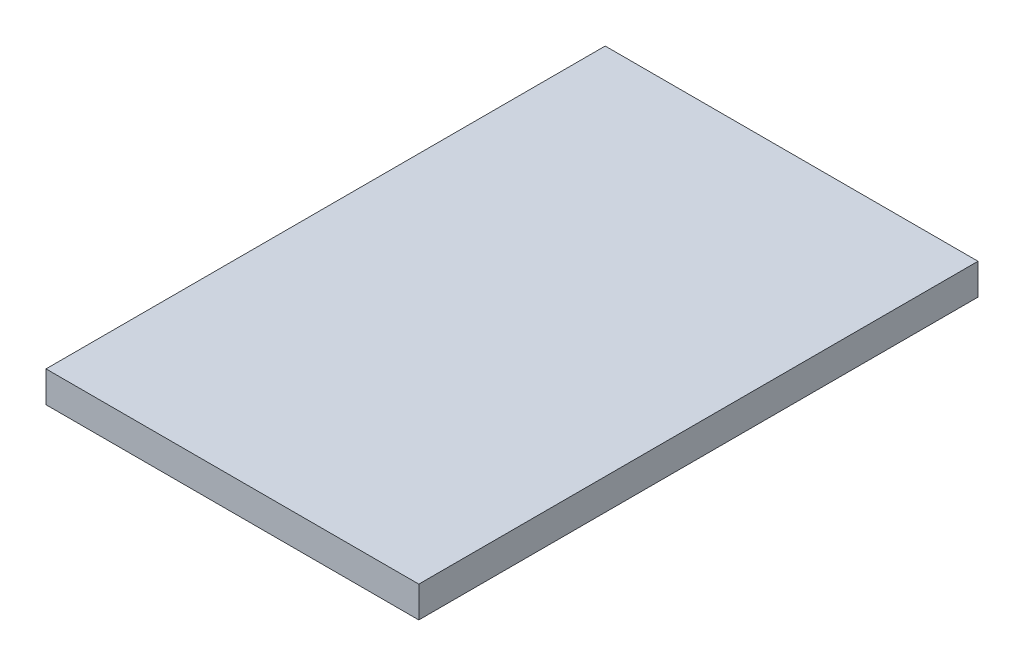
from build123d import *

# Parameters (mm, degrees)
SKETCH1_W           = 304.8
SKETCH1_H           = 25.4
BOSS_EXTRUDE1_DEPTH = 457.2


with BuildPart() as part:
    # Sketch1 → Boss-Extrude1 (new body)
    with BuildSketch(Plane.XY):
        Rectangle(SKETCH1_W, SKETCH1_H)
    extrude(amount=BOSS_EXTRUDE1_DEPTH)


solid = part.part
